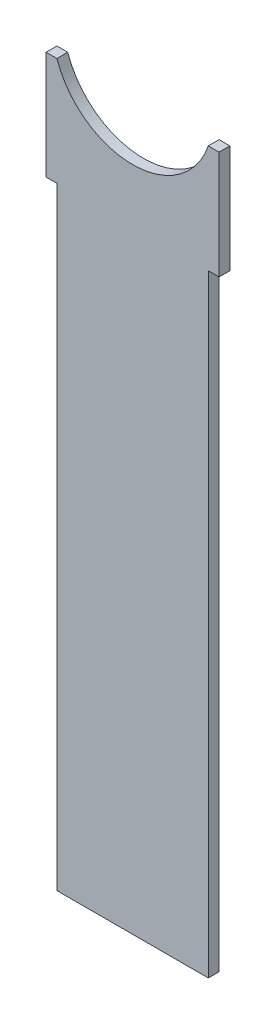
from build123d import *

# Parameters (mm, degrees)
SKETCH2_W           = 1.5875
SKETCH2_H           = 15.875
BOSS_EXTRUDE1_DEPTH = 1.5875


with BuildPart() as part:
    # Sketch2 → Boss-Extrude1 (new body)
    with BuildSketch(Plane.XY):
        with BuildLine():
            ThreePointArc((11.1125, 0), (0, -7.9375), (-11.1125, 0))
            Line((-11.1125, 0), (-11.1125, -15.875))
            Line((-11.1125, -15.875), (-11.1125, -105.804584263))
            Line((-11.1125, -105.804584263), (11.1125, -105.804584263))
            Line((11.1125, -105.804584263), (11.1125, -15.875))
            Line((11.1125, -15.875), (11.1125, 0))
        make_face()
        with Locations((-11.90625, -7.9375)):
            Rectangle(SKETCH2_W, SKETCH2_H)
        with Locations((11.90625, -7.9375)):
            Rectangle(SKETCH2_W, SKETCH2_H)
    extrude(amount=BOSS_EXTRUDE1_DEPTH)


solid = part.part
